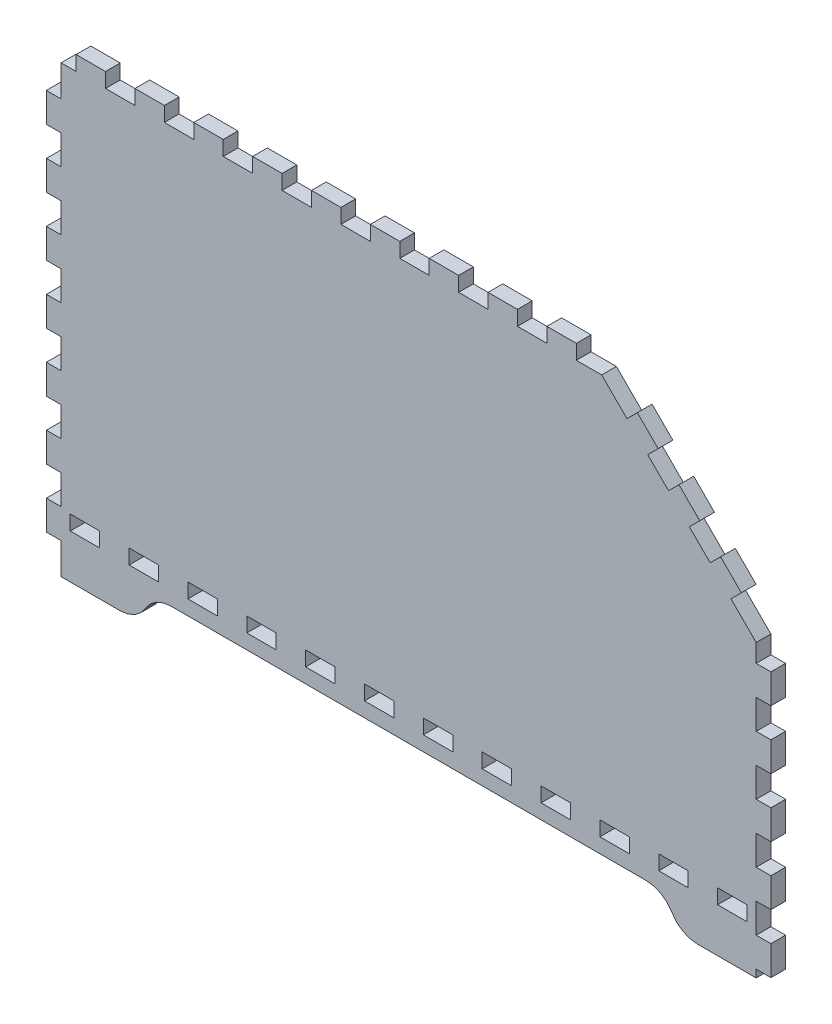
from build123d import *

# Parameters (mm, degrees)
BOSS_EXTRUDE1_DEPTH = 5.715


with BuildPart() as part:
    # Model → Boss-Extrude1 (new body)
    with BuildSketch(Plane.XY):
        Polygon((16.115014462, 22.860238699), (38.975005129, 22.860238699), (41.932961262, 23.249623789), (44.690011654, 24.391232573), (47.057297821, 26.208001576), (48.873953439, 28.575245224), (50.690254725, 30.942499501), (53.057186561, 32.759257875), (55.814102307, 33.900880832), (58.772193086, 34.290251749), (243.45807324, 34.290251749), (246.416029373, 33.900880832), (249.173079765, 32.759257875), (251.539834435, 30.942499501), (253.355958556, 28.575245224), (255.172925985, 26.208001576), (257.540254672, 24.391232573), (260.297170418, 23.249623789), (263.255261197, 22.860238699), (286.114932966, 22.860238699), (286.114932966, 25.834246031), (291.829939491, 25.834246031), (291.829939491, 37.264294514), (286.114932966, 37.264294514), (286.114932966, 48.694307564), (291.829939491, 48.694307564), (291.829939491, 60.124320614), (286.114932966, 60.124320614), (286.114932966, 71.554333664), (291.829939491, 71.554333664), (291.829939491, 82.984346714), (286.114932966, 82.984346714), (286.114932966, 94.414359764), (291.829939491, 94.414359764), (291.829939491, 105.844372814), (286.114932966, 105.844372814), (286.114932966, 117.274385864), (291.829939491, 117.274385864), (291.829939491, 128.704398914), (286.114932966, 128.704398914), (286.114932966, 131.679362941), (286.114932966, 135.720154956), (276.321220997, 145.514221256), (280.362013012, 149.556430596), (272.279011657, 157.638368957), (268.238219642, 153.597222611), (260.15592695, 161.679160972), (264.197073296, 165.720307318), (256.115134935, 173.80224568), (252.073988588, 169.761453665), (243.992050227, 177.843392026), (248.033196573, 181.884184041), (239.951258212, 189.967185396), (235.909048873, 185.926393381), (226.114982572, 195.720459681), (222.074190557, 195.720459681), (216.248987056, 195.720459681), (216.248987056, 201.435466206), (204.818974006, 201.435466206), (204.818974006, 195.720459681), (193.388960956, 195.720459681), (193.388960956, 201.435466206), (181.958947906, 201.435466206), (181.958947906, 195.720459681), (170.528934856, 195.720459681), (170.528934856, 201.435466206), (159.098921806, 201.435466206), (159.098921806, 195.720459681), (147.668908756, 195.720459681), (147.668908756, 201.435466206), (136.238895706, 201.435466206), (136.238895706, 195.720459681), (124.808882656, 195.720459681), (124.808882656, 201.435466206), (113.378869606, 201.435466206), (113.378869606, 195.720459681), (101.949210887, 195.720459681), (101.949210887, 201.435466206), (90.519197837, 201.435466206), (90.519197837, 195.720459681), (79.089184787, 195.720459681), (79.089184787, 201.435466206), (67.659171737, 201.435466206), (67.659171737, 195.720459681), (56.229158687, 195.720459681), (56.229158687, 201.435466206), (44.799145637, 201.435466206), (44.799145637, 195.720459681), (33.369026287, 195.720459681), (33.369026287, 201.435466206), (21.939013237, 201.435466206), (21.939013237, 195.720459681), (16.115014462, 195.720459681), (16.115014462, 183.585327716), (10.400007937, 183.585327716), (10.400007937, 172.155314666), (16.115014462, 172.155314666), (16.115014462, 160.725301616), (10.400007937, 160.725301616), (10.400007937, 149.295288565), (16.115014462, 149.295288565), (16.115014462, 137.865275515), (10.400007937, 137.865275515), (10.400007937, 126.435262465), (16.115014462, 126.435262465), (16.115014462, 115.005249415), (10.400007937, 115.005249415), (10.400007937, 103.575236365), (16.115014462, 103.575236365), (16.115014462, 92.145223315), (10.400007937, 92.145223315), (10.400007937, 80.715210265), (16.115014462, 80.715210265), (16.115014462, 69.285197215), (10.400007937, 69.285197215), (10.400007937, 57.855184165), (16.115014462, 57.855184165), (16.115014462, 46.425171115), (10.400007937, 46.425171115), (10.400007937, 34.995264365), (16.115014462, 34.995264365), align=None)
        Polygon((25.385025046, 40.005400006), (19.670018521, 40.005400006), (19.670018521, 45.720406531), (31.099996138, 45.720406531), (31.099996138, 40.005400006), align=None, mode=Mode.SUBTRACT)
        Polygon((48.245015713, 40.005400006), (42.530009188, 40.005400006), (42.530009188, 45.720406531), (53.960022238, 45.720406531), (53.960022238, 40.005400006), align=None, mode=Mode.SUBTRACT)
        Polygon((71.105041813, 40.005400006), (65.390035288, 40.005400006), (65.390035288, 45.720406531), (76.820048338, 45.720406531), (76.820048338, 40.005400006), align=None, mode=Mode.SUBTRACT)
        Polygon((93.965067913, 40.005400006), (88.250061388, 40.005400006), (88.250061388, 45.720406531), (99.680074438, 45.720406531), (99.680074438, 40.005400006), align=None, mode=Mode.SUBTRACT)
        Polygon((116.825094013, 40.005400006), (111.110087488, 40.005400006), (111.110087488, 45.720406531), (122.540100538, 45.720406531), (122.540100538, 40.005400006), align=None, mode=Mode.SUBTRACT)
        Polygon((139.685120113, 40.005400006), (133.970113588, 40.005400006), (133.970113588, 45.720406531), (145.400126638, 45.720406531), (145.400126638, 40.005400006), align=None, mode=Mode.SUBTRACT)
        Polygon((162.545146213, 40.005400006), (156.830139688, 40.005400006), (156.830139688, 45.720406531), (168.260152738, 45.720406531), (168.260152738, 40.005400006), align=None, mode=Mode.SUBTRACT)
        Polygon((185.405172313, 40.005400006), (179.690165788, 40.005400006), (179.690165788, 45.720406531), (191.120178838, 45.720406531), (191.120178838, 40.005400006), align=None, mode=Mode.SUBTRACT)
        Polygon((208.265198413, 40.005400006), (202.550191888, 40.005400006), (202.550191888, 45.720406531), (213.980204938, 45.720406531), (213.980204938, 40.005400006), align=None, mode=Mode.SUBTRACT)
        Polygon((231.125224513, 40.005400006), (225.410217988, 40.005400006), (225.410217988, 45.720406531), (236.840231038, 45.720406531), (236.840231038, 40.005400006), align=None, mode=Mode.SUBTRACT)
        Polygon((253.985250613, 40.005400006), (248.270244088, 40.005400006), (248.270244088, 45.720406531), (259.700257138, 45.720406531), (259.700257138, 40.005400006), align=None, mode=Mode.SUBTRACT)
        Polygon((276.844922382, 40.005400006), (271.130270188, 40.005400006), (271.130270188, 45.720406531), (282.559928907, 45.720406531), (282.559928907, 40.005400006), align=None, mode=Mode.SUBTRACT)
    extrude(amount=BOSS_EXTRUDE1_DEPTH)


solid = part.part
